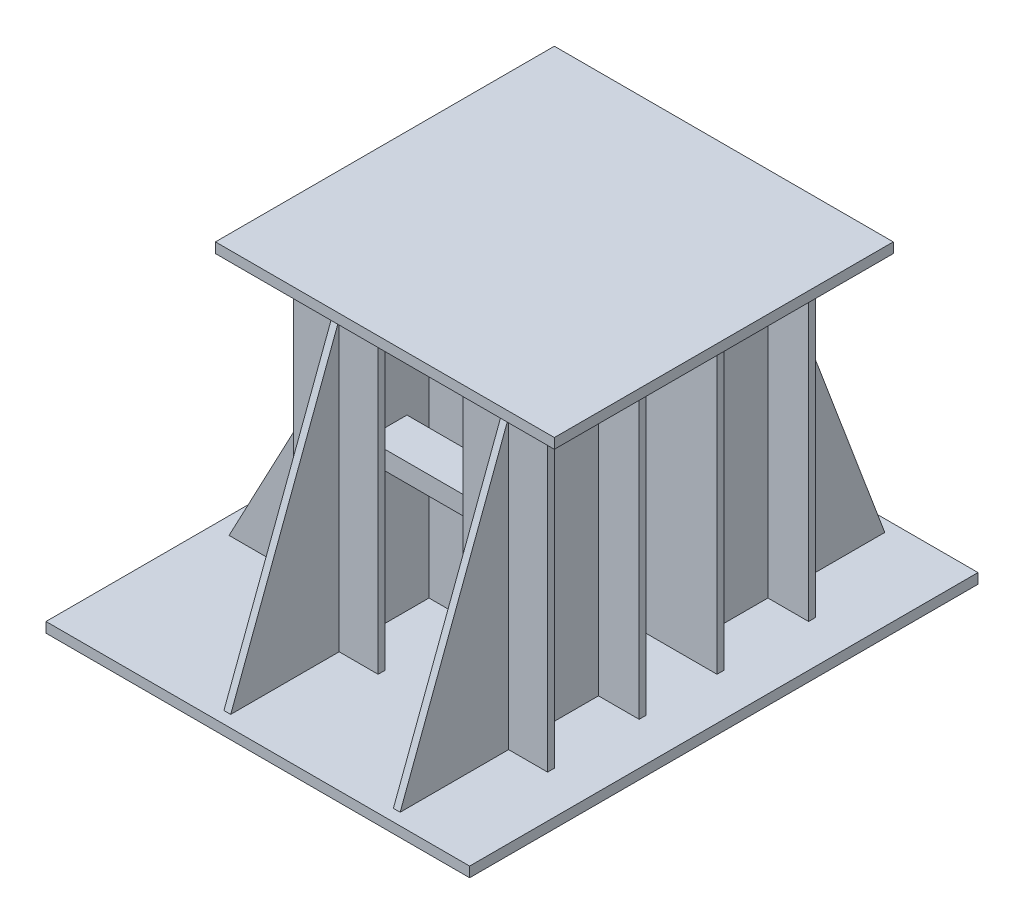
from build123d import *

# Parameters (mm, degrees)
SKETCH5_W           = 1000
SKETCH5_H           = 1000
BOSS_EXTRUDE1_DEPTH = 30
BOSS_EXTRUDE2_DEPTH = 940
SKETCH7_W           = 1250
SKETCH7_H           = 1500
BOSS_EXTRUDE3_DEPTH = 30
BOSS_EXTRUDE4_DEPTH = 445
CUT_EXTRUDE2_DEPTH  = 30
CUT_EXTRUDE3_DEPTH  = 30
SKETCH12_W          = 20
SKETCH12_H          = 850
BOSS_EXTRUDE5_DEPTH = 320
CUT_EXTRUDE4_DEPTH  = 700
BOSS_EXTRUDE6_DEPTH = 210
BOSS_EXTRUDE7_DEPTH = 490


with BuildPart() as part:
    # Sketch5 → Boss-Extrude1 (new body)
    with BuildSketch(Plane(origin=(0, 0, 0), x_dir=(1, 0, 0), z_dir=(0, 1, 0))):
        with Locations((-269.230769231, -730.850115694)):
            Rectangle(SKETCH5_W, SKETCH5_H)
    extrude(amount=BOSS_EXTRUDE1_DEPTH)

    # Sketch6 → Boss-Extrude2 (add)
    with BuildSketch(Plane.XZ):
        Polygon((-644.230769231, 625.850115694), (-644.230769231, 605.850115694), (-524.088400017, 605.850115694), (-524.088400017, 355.850115694), (-644.088400017, 355.850115694), (-644.088400017, 335.850115694), (-394.088400017, 335.850115694), (-394.088400017, 355.850115694), (-514.088400017, 355.850115694), (-514.088400017, 605.850115694), (-394.230769231, 605.850115694), (-394.230769231, 625.850115694), align=None)
        Polygon((-644.230769231, 1125.850115694), (-644.230769231, 1105.850115694), (-524.088400017, 1105.850115694), (-524.088400017, 855.850115694), (-644.088400017, 855.850115694), (-644.088400017, 835.850115694), (-394.088400017, 835.850115694), (-394.088400017, 855.850115694), (-514.088400017, 855.850115694), (-514.088400017, 1105.850115694), (-394.230769231, 1105.850115694), (-394.230769231, 1125.850115694), align=None)
        Polygon((-144.230769231, 1125.850115694), (-144.230769231, 1105.850115694), (-24.088400017, 1105.850115694), (-24.088400017, 855.850115694), (-144.088400017, 855.850115694), (-144.088400017, 835.850115694), (105.911599983, 835.850115694), (105.911599983, 855.850115694), (-14.088400017, 855.850115694), (-14.088400017, 1105.850115694), (105.769230769, 1105.850115694), (105.769230769, 1125.850115694), align=None)
        Polygon((-144.230769231, 625.850115694), (-144.230769231, 605.850115694), (-24.088400017, 605.850115694), (-24.088400017, 355.850115694), (-144.088400017, 355.850115694), (-144.088400017, 335.850115694), (105.911599983, 335.850115694), (105.911599983, 355.850115694), (-14.088400017, 355.850115694), (-14.088400017, 605.850115694), (105.769230769, 605.850115694), (105.769230769, 625.850115694), align=None)
    extrude(amount=BOSS_EXTRUDE2_DEPTH)

    # Sketch7 → Boss-Extrude3 (add)
    with BuildSketch(Plane.XZ.offset(940)):
        with Locations((-394.230769231, 730.850115694)):
            Rectangle(SKETCH7_W, SKETCH7_H)
    extrude(amount=BOSS_EXTRUDE3_DEPTH)

    # Sketch8 → Boss-Extrude4 (add)
    with BuildSketch(Plane.ZY.offset(524.088400017)):
        Polygon((480.850115694, -100), (470.850115694, -100), (470.850115694, -940), (490.850115694, -940), (490.850115694, -100), align=None)
        Polygon((975.850115694, -100), (970.850115694, -100), (970.850115694, -940), (990.850115694, -940), (990.850115694, -100), align=None)
    extrude(amount=BOSS_EXTRUDE4_DEPTH)

    # Sketch10 → Cut-Extrude2 (cut)
    with BuildSketch(Plane(origin=(0, 0, 470.850115694), x_dir=(-1, 0, 0), z_dir=(0, 0, -1))):
        Polygon((524.088400017, -100), (969.088400017, -940), (969.088400017, -100), align=None)
    extrude(amount=-CUT_EXTRUDE2_DEPTH, mode=Mode.SUBTRACT)

    # Sketch11 → Cut-Extrude3 (cut)
    with BuildSketch(Plane.XY.offset(990.850115694)):
        Polygon((-969.088400017, -100), (-524.088400017, -100), (-969.088400017, -940), align=None)
    extrude(amount=-CUT_EXTRUDE3_DEPTH, mode=Mode.SUBTRACT)

    # Sketch12 → Boss-Extrude5 (add)
    with BuildSketch(Plane.XY.offset(1125.850115694)):
        with Locations((-519.230769231, -515)):
            Rectangle(SKETCH12_W, SKETCH12_H)
        with Locations((-19.230769231, -515)):
            Rectangle(SKETCH12_W, SKETCH12_H)
    boss_extrude5 = extrude(amount=BOSS_EXTRUDE5_DEPTH)

    # Sketch13 → Cut-Extrude4 (cut)
    with BuildSketch(Plane.ZY.offset(529.230769231)):
        Polygon((1125.850115694, -90), (1445.850115694, -940), (1445.850115694, -90), align=None)
    cut_extrude4 = extrude(amount=-CUT_EXTRUDE4_DEPTH, mode=Mode.SUBTRACT)

    # Mirror1: Boss-Extrude5 across plane
    add(boss_extrude5.mirror(Plane(origin=(0, 0, 730.850115694), x_dir=(1, 0, 0), z_dir=(0, 0, -1))))

    # Mirror2: Cut-Extrude4 across plane
    add(cut_extrude4.mirror(Plane(origin=(0, 0, 730.850115694), x_dir=(1, 0, 0), z_dir=(0, 0, -1))), mode=Mode.SUBTRACT)

    # Sketch15 → Boss-Extrude6 (add)
    with BuildSketch(Plane(origin=(0, 0, 835.850115694), x_dir=(-1, 0, 0), z_dir=(0, 0, -1))):
        Polygon((549.088400017, -495), (579.088400017, -495), (579.088400017, -440), (459.088400017, -440), (459.088400017, -495), (489.088400017, -495), (489.088400017, -470), (549.088400017, -470), align=None)
    extrude(amount=BOSS_EXTRUDE6_DEPTH)

    # Sketch18 → Boss-Extrude7 (add)
    with BuildSketch(Plane(origin=(-514.088400017, 0, 0), x_dir=(0, 0, -1), z_dir=(1, 0, 0))):
        Polygon((-950.850115694, -495), (-920.850115694, -495), (-920.850115694, -440), (-1040.850115694, -440), (-1040.850115694, -495), (-1010.850115694, -495), (-1010.850115694, -470), (-950.850115694, -470), align=None)
    boss_extrude7 = extrude(amount=BOSS_EXTRUDE7_DEPTH)

    # Mirror3: Boss-Extrude7 across plane
    add(boss_extrude7.mirror(Plane(origin=(0, 0, 730.850115694), x_dir=(1, 0, 0), z_dir=(0, 0, -1))))


solid = part.part
